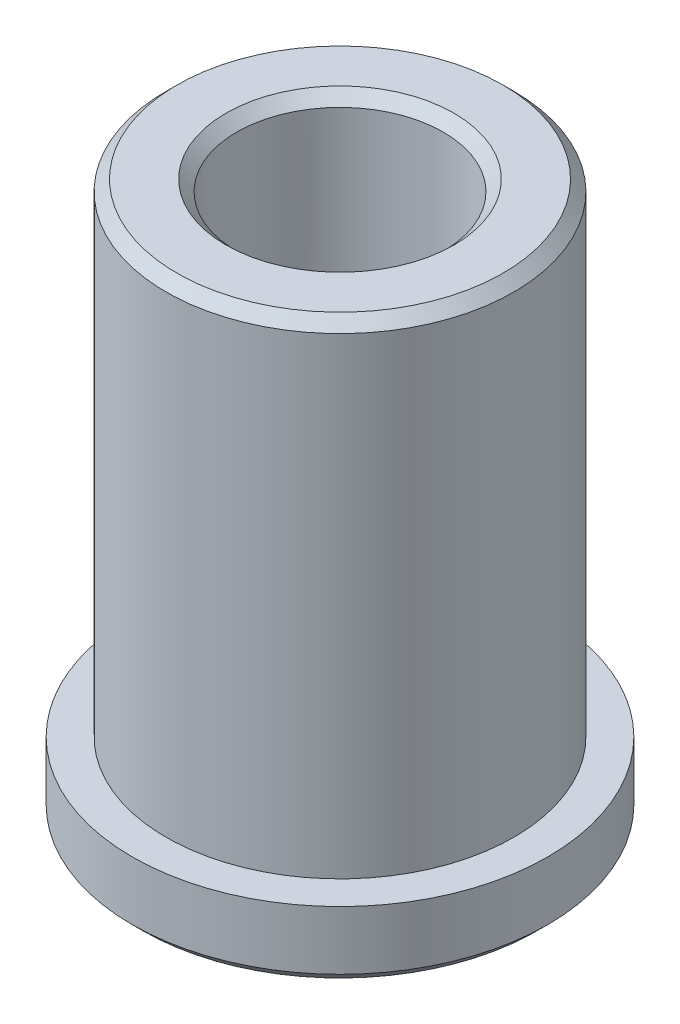
from build123d import *

# Parameters (mm, degrees)
CHAMFER1_SIZE = 0.25


with BuildPart() as part:
    # Sketch1 → Revolve1 (revolve)
    with BuildSketch(Plane.XY):
        Polygon((-2.375, 0), (-2.375, 12.7125), (-4, 12.7125), (-4, 1.6), (-4.78, 1.6), (-4.78, 0), align=None)
    revolve(axis=Axis((0, 0, 0), (0, 1, 0)))

    # Chamfer1
    chamfer1_edges = [part.edges().sort_by_distance(p)[0] for p in [
        (4.78, 0, 0),
        (4, 12.7125, 0),
        (2.375, 12.7125, 0),
        (2.375, 0, 0),
    ]]
    chamfer(chamfer1_edges, length=CHAMFER1_SIZE)


solid = part.part
